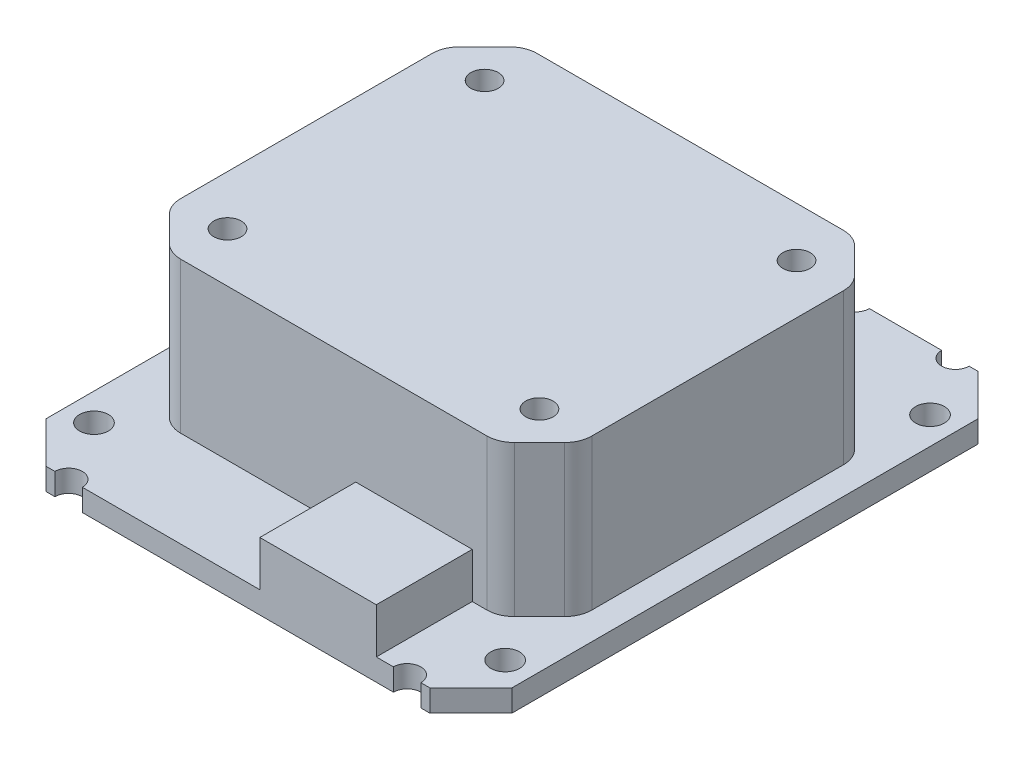
from build123d import *

# Parameters (mm, degrees)
BOSS_EXTRUDE1_DEPTH                        = 1.6
CHAMFER1_SIZE                              = 3
BOSS_EXTRUDE2_DEPTH                        = 11
CHAMFER2_SIZE                              = 3
FILLET1_R                                  = 2
SKETCH3_R                                  = 1
CUT_EXTRUDE1_DEPTH                         = 11
SKETCH4_R                                  = 1.05
CUT_EXTRUDE2_DEPTH                         = 13.6
SKETCH5_R                                  = 1
CUT_EXTRUDE3_DEPTH                         = 2.6
MIRROR1_AT_THE_SECOND_PLANE_COPY_1_SKETC_R = 1
MIRROR1_AT_THE_SECOND_PLANE_COPY_1_DEPTH   = 11
MIRROR1_AT_THE_SECOND_PLANE_COPY_2_SKETC_R = 1.05
MIRROR1_AT_THE_SECOND_PLANE_COPY_2_DEPTH   = 13.6
MIRROR1_AT_THE_SECOND_PLANE_COPY_3_SKETC_R = 1
MIRROR1_AT_THE_SECOND_PLANE_COPY_3_DEPTH   = 2.6
SKETCH6_W                                  = 8.5
SKETCH6_H                                  = 7
BOSS_EXTRUDE3_DEPTH                        = 3.3
SKETCH7_R                                  = 0.5
SKETCH7_R_2                                = 1
CUT_EXTRUDE4_DEPTH                         = 2.6
LPATTERN1_COUNT                            = 3
LPATTERN1_PITCH                            = 2.54
LPATTERN1_COL_COUNT                        = 3
LPATTERN1_COL_PITCH                        = 2.54


with BuildPart() as part:
    # Sketch1 → Boss-Extrude1 (new body)
    with BuildSketch(Plane(origin=(0, 0, 0), x_dir=(1, 0, 0), z_dir=(0, 1, 0))):
        Polygon((-17, 20), (-17, -20), (17, -20), align=None)
        Polygon((17, 20), (17, -20), (-17, 20), align=None)
    extrude(amount=BOSS_EXTRUDE1_DEPTH)

    # Chamfer1
    chamfer1_edges = [part.edges().sort_by_distance(p)[0] for p in [
        (-17, 0.8, -20),
        (17, 0.8, -20),
        (17, 0.8, 20),
        (-17, 0.8, 20),
    ]]
    chamfer(chamfer1_edges, length=CHAMFER1_SIZE)

    # Sketch2 → Boss-Extrude2 (add)
    with BuildSketch(Plane(origin=(0, 1.6, 0), x_dir=(1, 0, 0), z_dir=(0, 1, 0))):
        Polygon((-15, 13), (15, 13), (15, -13), align=None)
        Polygon((-15, 13), (15, -13), (-15, -13), align=None)
    extrude(amount=BOSS_EXTRUDE2_DEPTH)

    # Chamfer2
    chamfer2_edges = [part.edges().sort_by_distance(p)[0] for p in [
        (15, 7.1, -13),
        (-15, 7.1, -13),
        (-15, 7.1, 13),
        (15, 7.1, 13),
    ]]
    chamfer(chamfer2_edges, length=CHAMFER2_SIZE)

    # Fillet1
    fillet1_edges = [part.edges().sort_by_distance(p)[0] for p in [
        (-15, 7.1, 10),
        (-15, 7.1, -10),
        (12, 7.1, -13),
        (-12, 7.1, -13),
        (15, 7.1, 10),
        (15, 7.1, -10),
        (-12, 7.1, 13),
        (12, 7.1, 13),
    ]]
    fillet(fillet1_edges, radius=FILLET1_R)

    # Sketch3 → Cut-Extrude1 (cut)
    with BuildSketch(Plane(origin=(0, 12.6, 0), x_dir=(1, 0, 0), z_dir=(0, 1, 0))):
        with Locations((-11.378679656, 9.378679656)):
            Circle(SKETCH3_R)
    cut_extrude1 = extrude(amount=-CUT_EXTRUDE1_DEPTH, mode=Mode.SUBTRACT)

    # Sketch4 → Cut-Extrude2 (cut, through all)
    with BuildSketch(Plane(origin=(0, 12.6, 0), x_dir=(1, 0, 0), z_dir=(0, 1, 0))):
        with Locations((15, 15.5)):
            Circle(SKETCH4_R)
    cut_extrude2 = extrude(amount=-CUT_EXTRUDE2_DEPTH, mode=Mode.SUBTRACT)

    # Sketch5 → Cut-Extrude3 (cut, through all)
    with BuildSketch(Plane(origin=(0, 1.6, 0), x_dir=(1, 0, 0), z_dir=(0, 1, 0))):
        with Locations((-12.35, 20)):
            Circle(SKETCH5_R)
    cut_extrude3 = extrude(amount=-CUT_EXTRUDE3_DEPTH, mode=Mode.SUBTRACT)

    # Mirror1: Cut-Extrude1, Cut-Extrude2, Cut-Extrude3 across plane
    add(cut_extrude1.mirror(Plane.XY), mode=Mode.SUBTRACT)
    add(cut_extrude2.mirror(Plane.XY), mode=Mode.SUBTRACT)
    add(cut_extrude3.mirror(Plane.XY), mode=Mode.SUBTRACT)

    # Mirror1 at the second plane: Cut-Extrude3, Cut-Extrude1, Cut-Extrude2 across plane
    add(cut_extrude3.mirror(Plane(origin=(0, 0, 0), x_dir=(0, 0, 1), z_dir=(1, 0, 0))), mode=Mode.SUBTRACT)
    add(cut_extrude1.mirror(Plane(origin=(0, 0, 0), x_dir=(0, 0, 1), z_dir=(1, 0, 0))), mode=Mode.SUBTRACT)
    add(cut_extrude2.mirror(Plane(origin=(0, 0, 0), x_dir=(0, 0, 1), z_dir=(1, 0, 0))), mode=Mode.SUBTRACT)

    # Mirror1 at the second plane copy 1 sketc → Mirror1 at the second plane copy 1 (cut)
    with BuildSketch(Plane(origin=(0, 12.6, 0), x_dir=(-1, 0, 0), z_dir=(0, 1, 0))):
        with Locations((-11.378679656, 9.378679656)):
            Circle(MIRROR1_AT_THE_SECOND_PLANE_COPY_1_SKETC_R)
    extrude(amount=-MIRROR1_AT_THE_SECOND_PLANE_COPY_1_DEPTH, mode=Mode.SUBTRACT)

    # Mirror1 at the second plane copy 2 sketc → Mirror1 at the second plane copy 2 (cut, through all)
    with BuildSketch(Plane(origin=(0, 12.6, 0), x_dir=(-1, 0, 0), z_dir=(0, 1, 0))):
        with Locations((15, 15.5)):
            Circle(MIRROR1_AT_THE_SECOND_PLANE_COPY_2_SKETC_R)
    extrude(amount=-MIRROR1_AT_THE_SECOND_PLANE_COPY_2_DEPTH, mode=Mode.SUBTRACT)

    # Mirror1 at the second plane copy 3 sketc → Mirror1 at the second plane copy 3 (cut, through all)
    with BuildSketch(Plane(origin=(0, 1.6, 0), x_dir=(-1, 0, 0), z_dir=(0, 1, 0))):
        with Locations((-12.35, 20)):
            Circle(MIRROR1_AT_THE_SECOND_PLANE_COPY_3_SKETC_R)
    extrude(amount=-MIRROR1_AT_THE_SECOND_PLANE_COPY_3_DEPTH, mode=Mode.SUBTRACT)

    # Sketch6 → Boss-Extrude3 (add)
    with BuildSketch(Plane(origin=(0, 1.6, 0), x_dir=(1, 0, 0), z_dir=(0, 1, 0))):
        with Locations((5.85, -16.5)):
            Rectangle(SKETCH6_W, SKETCH6_H)
    extrude(amount=BOSS_EXTRUDE3_DEPTH)

    # Sketch7 → Cut-Extrude4 (cut, through all)
    with BuildSketch(Plane(origin=(0, 1.6, 0), x_dir=(1, 0, 0), z_dir=(0, 1, 0))):
        with Locations((0, 18)):
            Circle(SKETCH7_R)
        with Locations((0, 20)):
            Circle(SKETCH7_R_2)
    cut_extrude4 = extrude(amount=-CUT_EXTRUDE4_DEPTH, mode=Mode.SUBTRACT)

    # LPattern1: Cut-Extrude4 ×3
    with Locations(*[(i * LPATTERN1_PITCH, 0, 0) for i in range(1, LPATTERN1_COUNT)]):
        add(cut_extrude4, mode=Mode.SUBTRACT)

    # LPattern1 col: Cut-Extrude4 ×3
    with Locations(*[(-i * LPATTERN1_COL_PITCH, 0, 0) for i in range(1, LPATTERN1_COL_COUNT)]):
        add(cut_extrude4, mode=Mode.SUBTRACT)


solid = part.part
